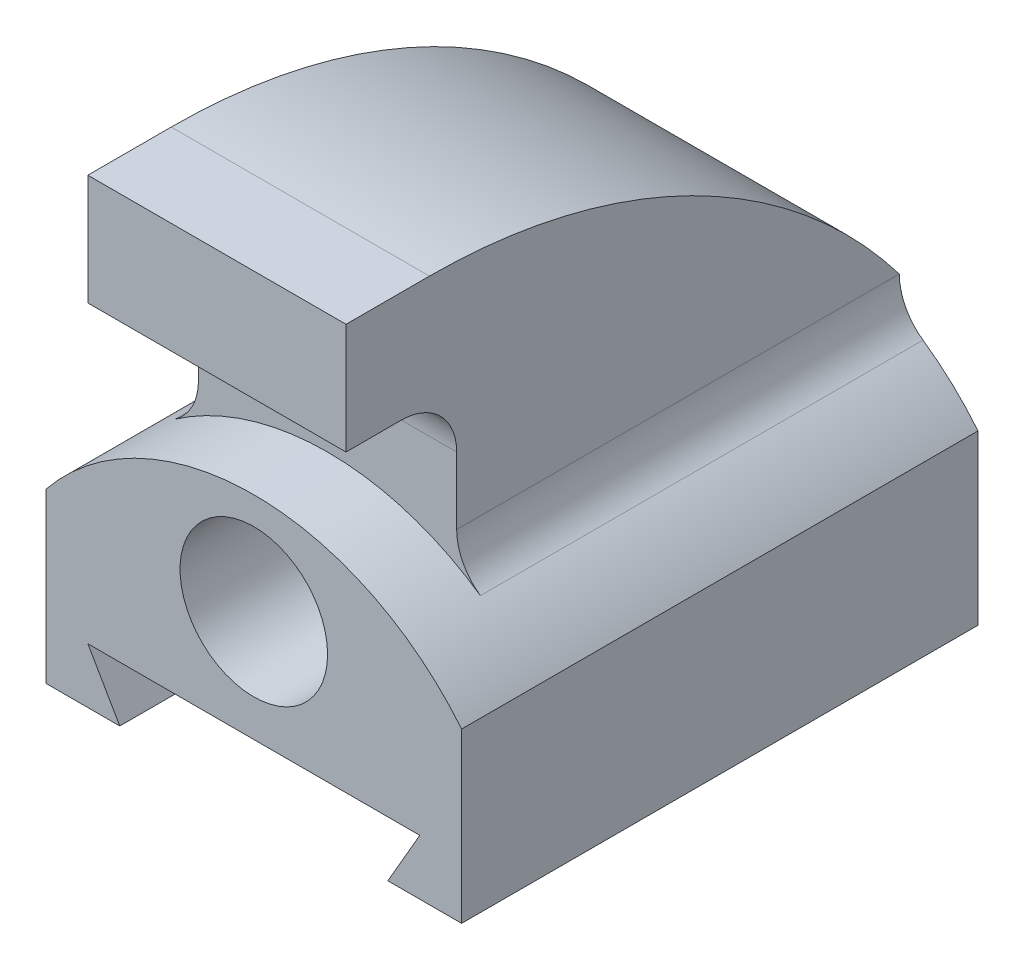
from build123d import *

# Parameters (mm, degrees)
SKETCH2_R           = 12.7
BOSS_EXTRUDE1_DEPTH = 44.45
BOSS_EXTRUDE3_START = -76.2
BOSS_EXTRUDE3_DEPTH = 76.2
SKETCH5_3_W         = 44.45
SKETCH5_3_H         = 19.05
BOSS_EXTRUDE4_DEPTH = 95.25
CUT_EXTRUDE2_DEPTH  = 109.402793728
FILLET1_R           = 9.525


with BuildPart() as part:
    # Sketch2 → Boss-Extrude1 (new, symmetric)
    with BuildSketch(Plane.XY):
        with BuildLine():
            Line((-28.575, 0), (28.575, 0))
            Line((28.575, 0), (23.075738686, -9.525))
            Line((23.075738686, -9.525), (28.575, -9.525))
            Line((28.575, -9.525), (35.775738686, -9.525))
            Line((35.775738686, -9.525), (35.775738686, 19.449953455))
            ThreePointArc((35.775738686, 19.449953455), (0, 36.5125), (-35.775738686, 19.449953455))
            Line((-35.775738686, 19.449953455), (-35.775738686, -9.525))
            Line((-35.775738686, -9.525), (-28.575, -9.525))
            Line((-28.575, -9.525), (-23.075738686, -9.525))
            Line((-23.075738686, -9.525), (-28.575, 0))
        make_face()
        with Locations((0, 19.05)):
            Circle(SKETCH2_R, mode=Mode.SUBTRACT)
    extrude(amount=BOSS_EXTRUDE1_DEPTH, both=True)

    # Sketch5 → Boss-Extrude3 (add)
    with BuildSketch(Plane(origin=(0, 0, -44.45), x_dir=(-1, 0, 0), z_dir=(0, 0, -1)).offset(BOSS_EXTRUDE3_START)):
        with BuildLine():
            ThreePointArc((26.307142857, 28.255757549), (23.306989894, 31.663247782), (22.225, 36.072466007))
            Line((22.225, 36.072466007), (22.225, 76.2))
            Line((22.225, 76.2), (-22.225, 76.2))
            Line((-22.225, 76.2), (-22.225, 36.072466007))
            ThreePointArc((-22.225, 36.072466007), (-23.306989894, 31.663247782), (-26.307142857, 28.255757549))
            ThreePointArc((-26.307142857, 28.255757549), (0, 36.5125), (26.307142857, 28.255757549))
        make_face()
    extrude(amount=BOSS_EXTRUDE3_DEPTH)

    # Sketch5_3 → Boss-Extrude4 (add)
    with BuildSketch(Plane(origin=(0, 0, -44.45), x_dir=(-1, 0, 0), z_dir=(0, 0, -1))):
        with Locations((0, 66.675)):
            Rectangle(SKETCH5_3_W, SKETCH5_3_H)
    extrude(amount=-BOSS_EXTRUDE4_DEPTH)

    # Sketch6 → Cut-Extrude2 (cut, through all)
    with BuildSketch(Plane(origin=(22.225, 0, 0), x_dir=(0, 0, -1), z_dir=(1, 0, 0))):
        with BuildLine():
            Line((44.45, 76.2), (-36.443114188, 76.2))
            ThreePointArc((-36.443114188, 76.2), (8.706401057, 65.616928498), (44.45, 36.072466007))
            Line((44.45, 36.072466007), (44.45, 76.2))
        make_face()
    extrude(amount=-CUT_EXTRUDE2_DEPTH, mode=Mode.SUBTRACT)

    # Fillet1
    fillet1_edges = [part.edges().sort_by_distance(p)[0] for p in [
        (0, 57.15, 31.75),
    ]]
    fillet(fillet1_edges, radius=FILLET1_R)


solid = part.part
